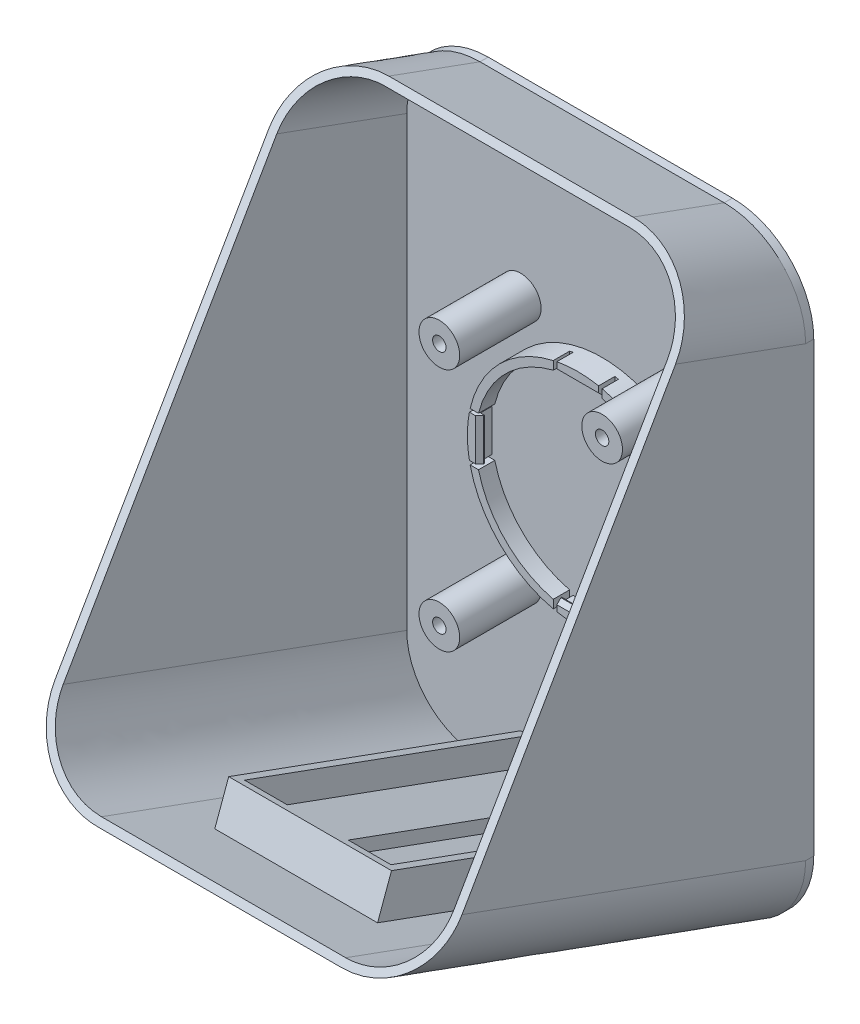
from build123d import *

# Parameters (mm, degrees)
AUFSATZ_LINEAR_AUSTRAGEN1_DEPTH      = 4
AUFSATZ_LINEAR_AUSTRAGEN1_2_DEPTH    = 4
AUFSATZ_LINEAR_AUSTRAGEN1_3_DEPTH    = 4
AUFSATZ_LINEAR_AUSTRAGEN1_4_DEPTH    = 4
SKIZZE2_R                            = 27.1
AUFSATZ_LINEAR_AUSTRAGEN2_DEPTH      = 2
AUFSATZ_LINEAR_AUSTRAGEN3_DEPTH      = 4
AUFSATZ_LINEAR_AUSTRAGEN4_DEPTH      = 10.258635
KREISMUSTER3_COUNT                   = 4
AUFSATZ_LINEAR_AUSTRAGEN5_DEPTH      = 2
SCHNITT_LINEAR_AUSTRAGEN1_DEPTH      = 1
SCHNITT_LINEAR_AUSTRAGEN1_DEPTH_BACK = 101
SKIZZE11_W                           = 40
SKIZZE11_H                           = 80
SKIZZE11_W_2                         = 36
SKIZZE11_H_2                         = 76
AUFSATZ_LINEAR_AUSTRAGEN6_DEPTH      = 10
AUFSATZ_LINEAR_AUSTRAGEN7_REACH      = 85.898
SKIZZE12_W                           = 7.5
SKIZZE12_H                           = 3
SCHNITT_LINEAR_AUSTRAGEN2_DEPTH      = 1.0000001
SCHNITT_LINEAR_AUSTRAGEN2_DEPTH_BACK = 101.0000001
SKIZZE14_R                           = 5
AUFSATZ_LINEAR_AUSTRAGEN8_DEPTH      = 20
KERNLOCH_F_R_M4_GEWINDE1_D           = 3.3
KERNLOCH_F_R_M4_GEWINDE1_DEPTH       = 20
KERNLOCH_F_R_M4_GEWINDE1_TIP         = 0.991420021


with BuildPart() as part:
    # Skizze1 → Aufsatz-Linear austragen1 (new body)
    with BuildSketch(Plane.XY):
        with BuildLine():
            Line((-6, -24.372320366), (-6, -26.427447853))
            ThreePointArc((-6, -26.427447853), (-19.16259377, -19.16259377), (-26.427447853, -6))
            Line((-26.427447853, -6), (-24.372320366, -6))
            ThreePointArc((-24.372320366, -6), (-17.748380208, -17.748380208), (-6, -24.372320366))
        make_face()
    extrude(amount=AUFSATZ_LINEAR_AUSTRAGEN1_DEPTH)



with BuildPart() as body_2:
    # Skizze1 → Aufsatz-Linear austragen1 2 (new body)
    with BuildSketch(Plane.XY):
        with BuildLine():
            Line((6, -24.372320366), (6, -26.427447853))
            ThreePointArc((6, -26.427447853), (19.16259377, -19.16259377), (26.427447853, -6))
            Line((26.427447853, -6), (24.372320366, -6))
            ThreePointArc((24.372320366, -6), (17.748380208, -17.748380208), (6, -24.372320366))
        make_face()
    extrude(amount=AUFSATZ_LINEAR_AUSTRAGEN1_2_DEPTH)


with BuildPart() as body_3:
    # Skizze1 → Aufsatz-Linear austragen1 3 (new body)
    with BuildSketch(Plane.XY):
        with BuildLine():
            Line((-24.372320366, 6), (-26.427447853, 6))
            ThreePointArc((-26.427447853, 6), (-19.16259377, 19.16259377), (-6, 26.427447853))
            Line((-6, 26.427447853), (-6, 24.372320366))
            ThreePointArc((-6, 24.372320366), (-17.748380208, 17.748380208), (-24.372320366, 6))
        make_face()
    extrude(amount=AUFSATZ_LINEAR_AUSTRAGEN1_3_DEPTH)


with BuildPart() as body_4:
    # Skizze1 → Aufsatz-Linear austragen1 4 (new body)
    with BuildSketch(Plane.XY):
        with BuildLine():
            Line((6, 24.372320366), (6, 26.427447853))
            ThreePointArc((6, 26.427447853), (19.16259377, 19.16259377), (26.427447853, 6))
            Line((26.427447853, 6), (24.372320366, 6))
            ThreePointArc((24.372320366, 6), (17.748380208, 17.748380208), (6, 24.372320366))
        make_face()
    extrude(amount=AUFSATZ_LINEAR_AUSTRAGEN1_4_DEPTH)


with BuildPart() as part_1:
    add(part.part)

    add(body_2.part)  # Aufsatz-Linear austragen2 merges body 2

    add(body_3.part)  # Aufsatz-Linear austragen2 merges body 3

    add(body_4.part)  # Aufsatz-Linear austragen2 merges body 4
    # Skizze2 → Aufsatz-Linear austragen2 (add)
    with BuildSketch(Plane(origin=(0, 0, 0), x_dir=(-1, 0, 0), z_dir=(0, 0, -1))):
        Circle(SKIZZE2_R)
    extrude(amount=AUFSATZ_LINEAR_AUSTRAGEN2_DEPTH)


with BuildPart() as body_2_2:
    # Skizze3 → Aufsatz-Linear austragen3 (new body)
    with BuildSketch(Plane.XY):
        with BuildLine():
            Line((5.129317712, -26.610150315), (5.129317712, -25.1))
            Line((5.129317712, -25.1), (0, -25.1))
            Line((0, -25.1), (-5.129317712, -25.1))
            Line((-5.129317712, -25.1), (-5.129317712, -26.610150315))
            ThreePointArc((-5.129317712, -26.610150315), (0, -27.1), (5.129317712, -26.610150315))
        make_face()
    extrude(amount=AUFSATZ_LINEAR_AUSTRAGEN3_DEPTH)


with BuildPart() as body_3_2:
    # Skizze4 → Aufsatz-Linear austragen4 (new body)
    with BuildSketch(Plane.ZY.offset(5.129317712)):
        Polygon((4, -25.1), (3, -24.1), (2.8, -24.1), (2.8, -25.1), align=None)
    extrude(amount=-AUFSATZ_LINEAR_AUSTRAGEN4_DEPTH)


with BuildPart() as kreismuster3_1:
    # Kreismuster3: pattern copy
    add(body_3_2.part.rotate(Axis((0, 0, 0), (0, 0, 1)), 1 * 360 / KREISMUSTER3_COUNT))


with BuildPart() as kreismuster3_2:
    # Kreismuster3: pattern copy
    add(body_3_2.part.rotate(Axis((0, 0, 0), (0, 0, 1)), 2 * 360 / KREISMUSTER3_COUNT))


with BuildPart() as kreismuster3_3:
    # Kreismuster3: pattern copy
    add(body_3_2.part.rotate(Axis((0, 0, 0), (0, 0, 1)), 3 * 360 / KREISMUSTER3_COUNT))


with BuildPart() as kreismuster3_4:
    # Kreismuster3: pattern copy
    add(body_2_2.part.rotate(Axis((0, 0, 0), (0, 0, 1)), 1 * 360 / KREISMUSTER3_COUNT))


with BuildPart() as kreismuster3_5:
    # Kreismuster3: pattern copy
    add(body_2_2.part.rotate(Axis((0, 0, 0), (0, 0, 1)), 2 * 360 / KREISMUSTER3_COUNT))


with BuildPart() as kreismuster3_6:
    # Kreismuster3: pattern copy
    add(body_2_2.part.rotate(Axis((0, 0, 0), (0, 0, 1)), 3 * 360 / KREISMUSTER3_COUNT))


with BuildPart() as part_2:
    add(part_1.part)

    # Kombinieren1: union Kreismuster3_6, Kreismuster3_5, Kreismuster3_4, body 2 2, Kreismuster3_3, Kreismuster3_2, Kreismuster3_1, body 3 2
    add(kreismuster3_6.part)
    add(kreismuster3_5.part)
    add(kreismuster3_4.part)
    add(body_2_2.part)
    add(kreismuster3_3.part)
    add(kreismuster3_2.part)
    add(kreismuster3_1.part)
    add(body_3_2.part)

    # Skizze5 → Aufsatz-Linear austragen5 (add)
    with BuildSketch(Plane(origin=(0, 0, -2), x_dir=(-1, 0, 0), z_dir=(0, 0, -1))):
        with BuildLine():
            Line((30, 75), (-30, 75))
            ThreePointArc((-30, 75), (-44.142135624, 69.142135624), (-50, 55))
            Line((-50, 55), (-50, -55))
            ThreePointArc((-50, -55), (-44.142135624, -69.142135624), (-30, -75))
            Line((-30, -75), (30, -75))
            ThreePointArc((30, -75), (44.142135624, -69.142135624), (50, -55))
            Line((50, -55), (50, 55))
            ThreePointArc((50, 55), (44.142135624, 69.142135624), (30, 75))
        make_face()
    extrude(amount=AUFSATZ_LINEAR_AUSTRAGEN5_DEPTH)

    # Austragung2: sweep along a path in Skizze7
    with BuildLine(Plane(origin=(0, 0, 0), x_dir=(0, 0, -1), z_dir=(1, 0, 0))) as austragung2_path:
        Line((2, 75), (-91.969262079, 109.202014333))
    # Skizze6 → Austragung2 (sweep)
    with BuildSketch(Plane.XY.offset(-2)):
        with BuildLine():
            Line((50, -55), (50, 55))
            ThreePointArc((50, 55), (44.142135624, 69.142135624), (30, 75))
            Line((30, 75), (-30, 75))
            ThreePointArc((-30, 75), (-44.142135624, 69.142135624), (-50, 55))
            Line((-50, 55), (-50, -55))
            ThreePointArc((-50, -55), (-44.142135624, -69.142135624), (-30, -75))
            Line((-30, -75), (30, -75))
            ThreePointArc((30, -75), (44.142135624, -69.142135624), (50, -55))
        make_face()
        with BuildLine():
            Line((48, -55), (48, 55))
            ThreePointArc((48, 55), (42.727922061, 67.727922061), (30, 73))
            Line((30, 73), (-30, 73))
            ThreePointArc((-30, 73), (-42.727922061, 67.727922061), (-48, 55))
            Line((-48, 55), (-48, -55))
            ThreePointArc((-48, -55), (-42.727922061, -67.727922061), (-30, -73))
            Line((-30, -73), (30, -73))
            ThreePointArc((30, -73), (42.727922061, -67.727922061), (48, -55))
        make_face(mode=Mode.SUBTRACT)
    sweep(path=austragung2_path.line)

    # Skizze8 → Schnitt-Linear austragen1 (cut, two sides)
    with BuildSketch(Plane(origin=(50, 0, 0), x_dir=(0, 0, -1), z_dir=(1, 0, 0))) as schnitt_linear_austragen1_sk:
        Polygon((-91.969262079, -20.797985667), (-82.427373137, -24.270949221), (-29.94698396, 66.627751236), (-91.969262079, 89.202014333), align=None)
        Polygon((-91.969262079, 89.202014333), (-29.94698396, 66.627751236), (-20.405095018, 83.154787683), (-91.969262079, 109.202014333), align=None)
        Polygon((-91.969262079, -20.797985667), (-91.969262079, -40.797985667), (-82.427373137, -24.270949221), align=None)
    extrude(amount=SCHNITT_LINEAR_AUSTRAGEN1_DEPTH, mode=Mode.SUBTRACT)
    extrude(schnitt_linear_austragen1_sk.sketch, amount=-SCHNITT_LINEAR_AUSTRAGEN1_DEPTH_BACK, mode=Mode.SUBTRACT)

    # Skizze11 → Aufsatz-Linear austragen6 (add)
    with BuildSketch(Plane(origin=(0, -63.817834564, 23.227792197), x_dir=(1, 0, 0), z_dir=(0, 0.939692621, -0.342020143))):
        with Locations((0, -13.153144296)):
            Rectangle(SKIZZE11_W, SKIZZE11_H)
        with Locations((0, -13.153144296)):
            Rectangle(SKIZZE11_W_2, SKIZZE11_H_2, mode=Mode.SUBTRACT)
    extrude(amount=AUFSATZ_LINEAR_AUSTRAGEN6_DEPTH)

    # Aufsatz-Linear austragen7: up to this face of the body (flat: up to its plane)
    aufsatz_linear_austragen7_end = Plane(part_2.part.faces().sort_by_distance((0, 0.797060642, -4))[0])
    # Skizze12 → Aufsatz-Linear austragen7 (add, up to the picked face)
    with BuildSketch(Plane(origin=(0, 18.17944603, 49.947617466), x_dir=(1, 0, 0), z_dir=(0, 0.342020143, 0.939692621)), mode=Mode.PRIVATE) as aufsatz_linear_austragen7_sk1:
        with Locations((-3.75, -59.413521031)):
            Rectangle(SKIZZE12_W, SKIZZE12_H)
    aufsatz_linear_austragen7_tool1 = split(extrude(aufsatz_linear_austragen7_sk1.sketch, amount=-AUFSATZ_LINEAR_AUSTRAGEN7_REACH, mode=Mode.PRIVATE), bisect_by=aufsatz_linear_austragen7_end, keep=Keep.BOTH, mode=Mode.PRIVATE)
    add(aufsatz_linear_austragen7_tool1.solids().sort_by_distance((-3.75, -37.651001, 70.268238))[0])
    # Skizze12 → Aufsatz-Linear austragen7 (add, up to the picked face)
    with BuildSketch(Plane(origin=(0, 18.17944603, 49.947617466), x_dir=(1, 0, 0), z_dir=(0, 0.342020143, 0.939692621)), mode=Mode.PRIVATE) as aufsatz_linear_austragen7_sk2:
        with Locations((3.75, -59.413521031)):
            Rectangle(SKIZZE12_W, SKIZZE12_H)
    aufsatz_linear_austragen7_tool2 = split(extrude(aufsatz_linear_austragen7_sk2.sketch, amount=-AUFSATZ_LINEAR_AUSTRAGEN7_REACH, mode=Mode.PRIVATE), bisect_by=aufsatz_linear_austragen7_end, keep=Keep.BOTH, mode=Mode.PRIVATE)
    add(aufsatz_linear_austragen7_tool2.solids().sort_by_distance((3.75, -37.651001, 70.268238))[0])

    # Skizze13 → Schnitt-Linear austragen2 (cut, two sides)
    with BuildSketch(Plane(origin=(50, 0, 0), x_dir=(0, 0, -1), z_dir=(1, 0, 0))) as schnitt_linear_austragen2_sk:
        Polygon((4, -47.000472849), (4, -75), (25.669622084, -47.000472849), align=None)
    extrude(amount=SCHNITT_LINEAR_AUSTRAGEN2_DEPTH, mode=Mode.SUBTRACT)
    extrude(schnitt_linear_austragen2_sk.sketch, amount=-SCHNITT_LINEAR_AUSTRAGEN2_DEPTH_BACK, mode=Mode.SUBTRACT)

    # Skizze14 → Aufsatz-Linear austragen8 (add)
    with BuildSketch(Plane(origin=(0, -99.846855704, -2), x_dir=(1, 0, 0), z_dir=(0, 0, 1))):
        with Locations((-20, 69.846855704)):
            Circle(SKIZZE14_R)
        with Locations((20, 69.846855704)):
            Circle(SKIZZE14_R)
        with Locations((-20, 129.846855704)):
            Circle(SKIZZE14_R)
        with Locations((20, 129.846855704)):
            Circle(SKIZZE14_R)
    extrude(amount=AUFSATZ_LINEAR_AUSTRAGEN8_DEPTH)

    # Kernloch für M4 Gewinde1
    with Locations(Plane.XY.offset(18)):
        with Locations((-20, 30), (20, 30), (20, -30), (-20, -30)):
            Hole(KERNLOCH_F_R_M4_GEWINDE1_D / 2, depth=KERNLOCH_F_R_M4_GEWINDE1_DEPTH)
            with Locations((0, 0, -(KERNLOCH_F_R_M4_GEWINDE1_DEPTH + KERNLOCH_F_R_M4_GEWINDE1_TIP / 2))):  # 118° drill point
                Cone(0, KERNLOCH_F_R_M4_GEWINDE1_D / 2, KERNLOCH_F_R_M4_GEWINDE1_TIP, mode=Mode.SUBTRACT)


solid = part_2.part
